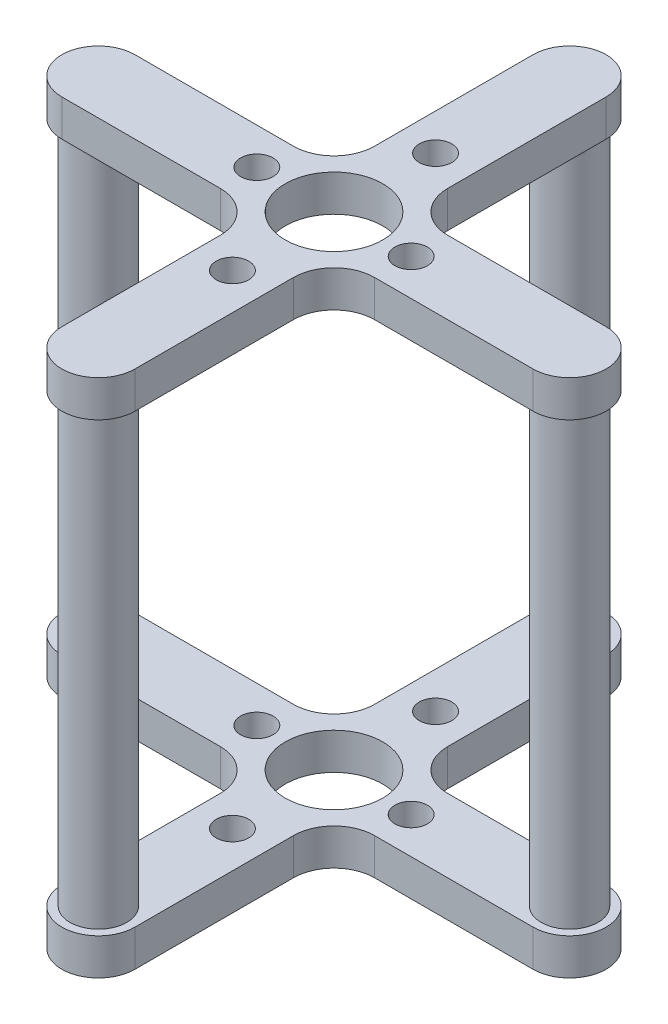
from build123d import *

# Parameters (mm, degrees)
BOSS_EXTRUDE1_DEPTH      = 4.5
SKETCH2_R                = 6
SKETCH2_R_2              = 2
SKETCH2_R_3              = 3.5
CUT_EXTRUDE1_DEPTH       = 5.5
FILLET1_R                = 5
SKETCH4_R                = 3.5
BOSS_EXTRUDE2_DEPTH      = 27.5
BOSS_EXTRUDE2_DEPTH_BACK = 4.5


with BuildPart() as part:
    # Sketch1 → Boss-Extrude1 (new body)
    with BuildSketch(Plane(origin=(0, 0, 0), x_dir=(1, 0, 0), z_dir=(0, 1, 0))):
        with BuildLine():
            Line((4.5, 29), (4.5, -29))
            ThreePointArc((4.5, -29), (0, -33.5), (-4.5, -29))
            Line((-4.5, -29), (-4.5, 29))
            ThreePointArc((-4.5, 29), (0, 33.5), (4.5, 29))
        make_face()
        with BuildLine():
            Line((29, -4.5), (-29, -4.5))
            ThreePointArc((-29, -4.5), (-33.5, 0), (-29, 4.5))
            Line((-29, 4.5), (29, 4.5))
            ThreePointArc((29, 4.5), (33.5, 0), (29, -4.5))
        make_face()
    extrude(amount=BOSS_EXTRUDE1_DEPTH)

    # Sketch2 → Cut-Extrude1 (cut, through all)
    with BuildSketch(Plane(origin=(0, 4.5, 0), x_dir=(1, 0, 0), z_dir=(0, 1, 0))):
        Circle(SKETCH2_R)
        with Locations((9.5, 0)):
            Circle(SKETCH2_R_2)
        with Locations((29, 0)):
            Circle(SKETCH2_R_3)
        with Locations((0, 12.5)):
            Circle(SKETCH2_R_2)
        with Locations((0, -29)):
            Circle(SKETCH2_R_3)
        with Locations((-29, 0)):
            Circle(SKETCH2_R_3)
        with Locations((0, 29)):
            Circle(SKETCH2_R_3)
        with Locations((-9.5, 0)):
            Circle(SKETCH2_R_2)
        with Locations((0, -12.5)):
            Circle(SKETCH2_R_2)
    extrude(amount=-CUT_EXTRUDE1_DEPTH, mode=Mode.SUBTRACT)

    # Fillet1
    fillet1_edges = [part.edges().sort_by_distance(p)[0] for p in [
        (4.5, 2.25, -4.5),
        (4.5, 2.25, 4.5),
        (-4.5, 2.25, -4.5),
        (-4.5, 2.25, 4.5),
    ]]
    fillet(fillet1_edges, radius=FILLET1_R)

    # Sketch4 → Boss-Extrude2 (add, two sides)
    with BuildSketch(Plane.XZ) as boss_extrude2_sk:
        with Locations((0, -29)):
            Circle(SKETCH4_R)
        with Locations((-29, 0)):
            Circle(SKETCH4_R)
        with Locations((0, 29)):
            Circle(SKETCH4_R)
        with Locations((29, 0)):
            Circle(SKETCH4_R)
    extrude(amount=BOSS_EXTRUDE2_DEPTH)
    extrude(boss_extrude2_sk.sketch, amount=-BOSS_EXTRUDE2_DEPTH_BACK)

    # Mirror2: part across plane


with BuildPart() as part_1:
    add(part.part)
    add(part.part.mirror(Plane(origin=(0, -27.5, 29), x_dir=(0, 0, 1), z_dir=(0, -1, 0))))


solid = part_1.part
